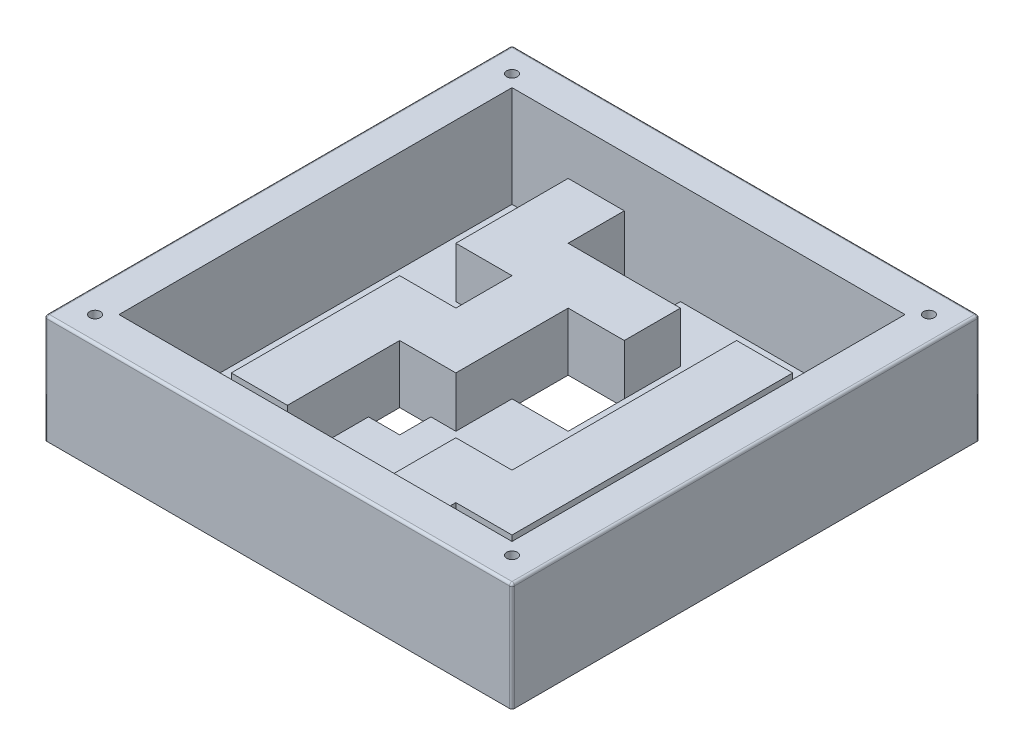
from build123d import *

# Parameters (mm, degrees)
ESQUISSE2_W             = 185
ESQUISSE2_H             = 185
BOSS_EXTRU_1_DEPTH      = 3
ESQUISSE3_W             = 185
ESQUISSE3_H             = 185
ESQUISSE3_W_2           = 155.54
ESQUISSE3_H_2           = 155.54
BOSS_EXTRU_2_DEPTH      = 40
BOSS_EXTRU_3_DEPTH      = 20
ENL_V_MAT_EXTRU_1_REACH = 5
ESQUISSE5_W             = 22.22
ESQUISSE5_H             = 22.22
ESQUISSE5_W_2           = 12.35
ESQUISSE5_H_2           = 12.35
CONG_1_R                = 1
ESQUISSE6_R             = 1.1
ENL_V_MAT_EXTRU_2_DEPTH = 44
ESQUISSE7_R             = 2.1
ENL_V_MAT_EXTRU_3_DEPTH = 41


with BuildPart() as part:
    # Esquisse2 → Boss.-Extru.1 (new body)
    with BuildSketch(Plane(origin=(0, 0, 0), x_dir=(1, 0, 0), z_dir=(0, 1, 0))):
        Rectangle(ESQUISSE2_W, ESQUISSE2_H)
    extrude(amount=-BOSS_EXTRU_1_DEPTH)

    # Esquisse3 → Boss.-Extru.2 (add)
    with BuildSketch(Plane(origin=(0, 0, 0), x_dir=(1, 0, 0), z_dir=(0, 1, 0))):
        Rectangle(ESQUISSE3_W, ESQUISSE3_H)
        Rectangle(ESQUISSE3_W_2, ESQUISSE3_H_2, mode=Mode.SUBTRACT)
    extrude(amount=BOSS_EXTRU_2_DEPTH)

    # Esquisse4 → Boss.-Extru.3 (add)
    with BuildSketch(Plane(origin=(0, 0, 0), x_dir=(1, 0, 0), z_dir=(0, 1, 0))):
        Polygon((-55.55, 77.77), (-33.33, 77.77), (-33.33, 55.55), (11.11, 55.55), (11.11, 33.33), (-11.11, 33.33), (-11.11, -11.11), (-33.33, -11.11), (-33.33, -55.55), (-55.55, -55.55), (-55.55, 11.11), (-33.33, 11.11), (-33.33, 33.33), (-55.55, 33.33), align=None)
        Polygon((33.33, 55.55), (55.55, 55.55), (55.55, -55.55), (33.33, -55.55), (33.33, -77.77), (11.11, -77.77), (11.11, -33.33), (33.33, -33.33), align=None)
    extrude(amount=BOSS_EXTRU_3_DEPTH)

    # Esquisse5 → Enlèv. mat.-Extru.1 (cut, up to next)
    with BuildSketch(Plane(origin=(0, 0, 0), x_dir=(1, 0, 0), z_dir=(0, 1, 0)), mode=Mode.PRIVATE) as enl_v_mat_extru_1_sk1:
        with Locations((-22.22, 66.66)):
            Rectangle(ESQUISSE5_W, ESQUISSE5_H)
    enl_v_mat_extru_1_tool1 = extrude(enl_v_mat_extru_1_sk1.sketch, amount=-ENL_V_MAT_EXTRU_1_REACH, mode=Mode.PRIVATE) & part.part
    add(enl_v_mat_extru_1_tool1.solids().sort_by_distance((-22.22, 0, -66.66))[0], mode=Mode.SUBTRACT)
    # Esquisse5 → Enlèv. mat.-Extru.1 (cut, up to next)
    with BuildSketch(Plane(origin=(0, 0, 0), x_dir=(1, 0, 0), z_dir=(0, 1, 0)), mode=Mode.PRIVATE) as enl_v_mat_extru_1_sk2:
        with Locations((0, 22.22)):
            Rectangle(ESQUISSE5_W, ESQUISSE5_H)
    enl_v_mat_extru_1_tool2 = extrude(enl_v_mat_extru_1_sk2.sketch, amount=-ENL_V_MAT_EXTRU_1_REACH, mode=Mode.PRIVATE) & part.part
    add(enl_v_mat_extru_1_tool2.solids().sort_by_distance((0, 0, -22.22))[0], mode=Mode.SUBTRACT)
    # Esquisse5 → Enlèv. mat.-Extru.1 (cut, up to next)
    with BuildSketch(Plane(origin=(0, 0, 0), x_dir=(1, 0, 0), z_dir=(0, 1, 0)), mode=Mode.PRIVATE) as enl_v_mat_extru_1_sk3:
        with Locations((-27.155, -17.285)):
            Rectangle(ESQUISSE5_W_2, ESQUISSE5_H_2)
    enl_v_mat_extru_1_tool3 = extrude(enl_v_mat_extru_1_sk3.sketch, amount=-ENL_V_MAT_EXTRU_1_REACH, mode=Mode.PRIVATE) & part.part
    add(enl_v_mat_extru_1_tool3.solids().sort_by_distance((-27.155, 0, 17.285))[0], mode=Mode.SUBTRACT)
    # Esquisse5 → Enlèv. mat.-Extru.1 (cut, up to next)
    with BuildSketch(Plane(origin=(0, 0, 0), x_dir=(1, 0, 0), z_dir=(0, 1, 0)), mode=Mode.PRIVATE) as enl_v_mat_extru_1_sk4:
        with Locations((-66.66, 22.22)):
            Rectangle(ESQUISSE5_W_2, ESQUISSE5_H_2)
    enl_v_mat_extru_1_tool4 = extrude(enl_v_mat_extru_1_sk4.sketch, amount=-ENL_V_MAT_EXTRU_1_REACH, mode=Mode.PRIVATE) & part.part
    add(enl_v_mat_extru_1_tool4.solids().sort_by_distance((-66.66, 0, -22.22))[0], mode=Mode.SUBTRACT)
    # Esquisse5 → Enlèv. mat.-Extru.1 (cut, up to next)
    with BuildSketch(Plane(origin=(0, 0, 0), x_dir=(1, 0, 0), z_dir=(0, 1, 0)), mode=Mode.PRIVATE) as enl_v_mat_extru_1_sk5:
        with Locations((-66.66, -66.66)):
            Rectangle(ESQUISSE5_W_2, ESQUISSE5_H_2)
    enl_v_mat_extru_1_tool5 = extrude(enl_v_mat_extru_1_sk5.sketch, amount=-ENL_V_MAT_EXTRU_1_REACH, mode=Mode.PRIVATE) & part.part
    add(enl_v_mat_extru_1_tool5.solids().sort_by_distance((-66.66, 0, 66.66))[0], mode=Mode.SUBTRACT)
    # Esquisse5 → Enlèv. mat.-Extru.1 (cut, up to next)
    with BuildSketch(Plane(origin=(0, 0, 0), x_dir=(1, 0, 0), z_dir=(0, 1, 0)), mode=Mode.PRIVATE) as enl_v_mat_extru_1_sk6:
        with Locations((66.66, -66.66)):
            Rectangle(ESQUISSE5_W_2, ESQUISSE5_H_2)
    enl_v_mat_extru_1_tool6 = extrude(enl_v_mat_extru_1_sk6.sketch, amount=-ENL_V_MAT_EXTRU_1_REACH, mode=Mode.PRIVATE) & part.part
    add(enl_v_mat_extru_1_tool6.solids().sort_by_distance((66.66, 0, 66.66))[0], mode=Mode.SUBTRACT)
    # Esquisse5 → Enlèv. mat.-Extru.1 (cut, up to next)
    with BuildSketch(Plane(origin=(0, 0, 0), x_dir=(1, 0, 0), z_dir=(0, 1, 0)), mode=Mode.PRIVATE) as enl_v_mat_extru_1_sk7:
        with Locations((4.935, -49.375)):
            Rectangle(ESQUISSE5_W_2, ESQUISSE5_H_2)
    enl_v_mat_extru_1_tool7 = extrude(enl_v_mat_extru_1_sk7.sketch, amount=-ENL_V_MAT_EXTRU_1_REACH, mode=Mode.PRIVATE) & part.part
    add(enl_v_mat_extru_1_tool7.solids().sort_by_distance((4.935, 0, 49.375))[0], mode=Mode.SUBTRACT)

    # Congé1
    cong_1_edges = [part.edges().sort_by_distance(p)[0] for p in [
        (-92.5, 40, 0),
        (0, 40, 92.5),
        (92.5, 40, 0),
        (0, 40, -92.5),
        (-92.5, 18.5, -92.5),
        (92.5, 18.5, -92.5),
        (92.5, 18.5, 92.5),
        (-92.5, 18.5, 92.5),
    ]]
    fillet(cong_1_edges, radius=CONG_1_R)

    # Esquisse6 → Enlèv. mat.-Extru.2 (cut, through all)
    with BuildSketch(Plane(origin=(0, 40, 0), x_dir=(1, 0, 0), z_dir=(0, 1, 0))):
        with Locations(Location((-82.5, -82.5, 0), (0, 0, 270))):  # turned: the seam where the file's is
            Circle(ESQUISSE6_R)
        with Locations(Location((82.5, -82.5, 0), (0, 0, 270))):  # turned: the seam where the file's is
            Circle(ESQUISSE6_R)
        with Locations(Location((82.5, 82.5, 0), (0, 0, 270))):  # turned: the seam where the file's is
            Circle(ESQUISSE6_R)
        with Locations(Location((-82.5, 82.5, 0), (0, 0, 270))):  # turned: the seam where the file's is
            Circle(ESQUISSE6_R)
    extrude(amount=-ENL_V_MAT_EXTRU_2_DEPTH, mode=Mode.SUBTRACT)

    # Esquisse7 → Enlèv. mat.-Extru.3 (cut)
    with BuildSketch(Plane(origin=(0, 40, 0), x_dir=(1, 0, 0), z_dir=(0, 1, 0))):
        with Locations(Location((-82.5, -82.5, 0), (0, 0, 270))):  # turned: the seam where the file's is
            Circle(ESQUISSE7_R)
        with Locations(Location((-82.5, 82.5, 0), (0, 0, 270))):  # turned: the seam where the file's is
            Circle(ESQUISSE7_R)
        with Locations(Location((82.5, 82.5, 0), (0, 0, 270))):  # turned: the seam where the file's is
            Circle(ESQUISSE7_R)
        with Locations(Location((82.5, -82.5, 0), (0, 0, 270))):  # turned: the seam where the file's is
            Circle(ESQUISSE7_R)
    extrude(amount=-ENL_V_MAT_EXTRU_3_DEPTH, mode=Mode.SUBTRACT)


solid = part.part
